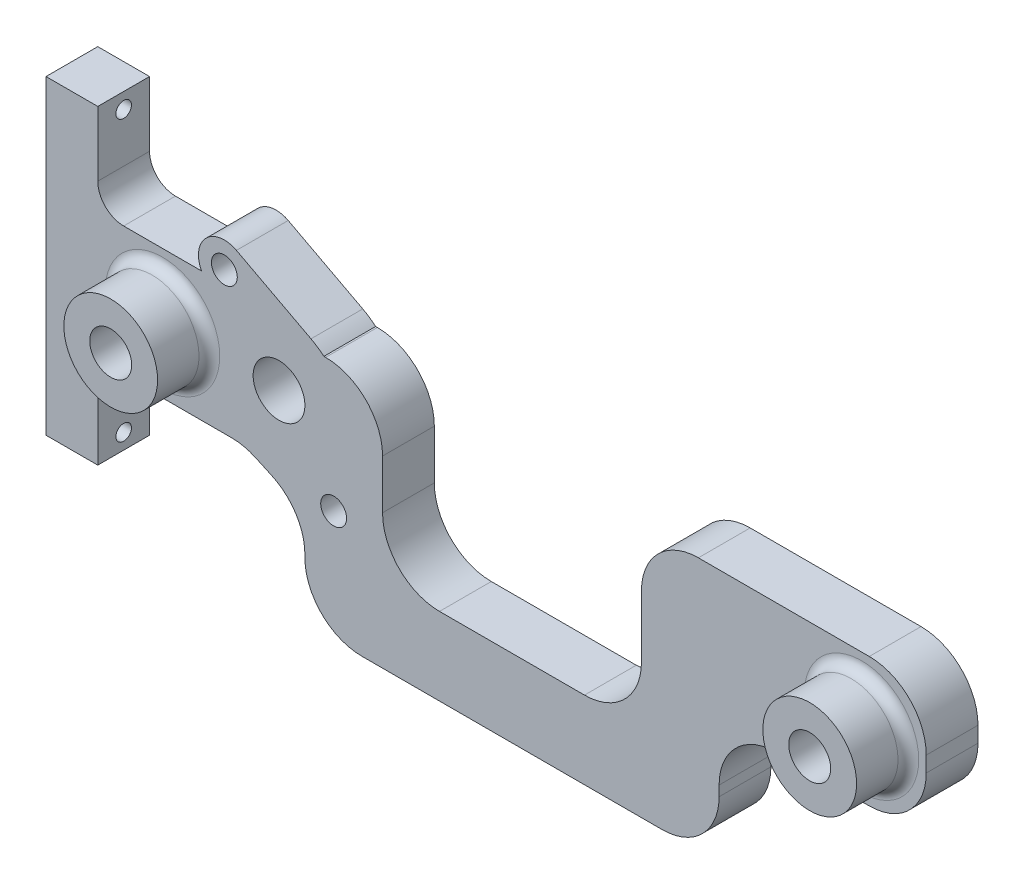
from build123d import *

# Parameters (mm, degrees)
SKETCH1_R           = 4.05
SKETCH1_R_2         = 5
SKETCH1_R_3         = 2.5
BOSS_EXTRUDE1_DEPTH = 10
FILLET1_R           = 11
SKETCH2_R           = 9.05
SKETCH2_R_2         = 4.05
BOSS_EXTRUDE2_DEPTH = 10
FILLET2_R           = 2
SKETCH3_W           = 10
SKETCH3_H           = 60
BOSS_EXTRUDE3_DEPTH = 10
FILLET3_R           = 5
SKETCH4_R           = 1.5
CUT_EXTRUDE1_DEPTH  = 10


with BuildPart() as part:
    # Sketch1 → Boss-Extrude1 (new body)
    with BuildSketch(Plane.XY):
        with BuildLine():
            Line((-80, -12.5), (-51.772571723, -12.5))
            Line((-51.772571723, -12.5), (-40, -17.854919158))
            Line((-40, -17.854919158), (-40, -36.461589484))
            Line((-40, -36.461589484), (40, -36.461589484))
            Line((40, -36.461589484), (40, -12.5))
            Line((40, -12.5), (80, -12.5))
            Line((80, -12.5), (80, 12.5))
            Line((80, 12.5), (25, 12.5))
            Line((25, 12.5), (25, -21.461589484))
            Line((25, -21.461589484), (-25, -21.461589484))
            Line((-25, -21.461589484), (-25, 10.023927765))
            Line((-25, 10.023927765), (-36.337703419, 10.023927765))
            ThreePointArc((-36.337703419, 10.023927765), (-37.531405043, 10.942330613), (-38.821632397, 11.719312422))
            Line((-38.821632397, 11.719312422), (-53.222645277, 19.311460171))
            ThreePointArc((-53.222645277, 19.311460171), (-59.112621671, 18.401196951), (-59.947052977, 12.5))
            Line((-59.947052977, 12.5), (-80, 12.5))
            Line((-80, 12.5), (-80, -12.5))
        make_face()
        with Locations((-67.5, 0)):
            Circle(SKETCH1_R, mode=Mode.SUBTRACT)
        with Locations((67.5, 0)):
            Circle(SKETCH1_R, mode=Mode.SUBTRACT)
        with Locations((-45, 0)):
            Circle(SKETCH1_R_2, mode=Mode.SUBTRACT)
        with Locations((-34.445576532, -14.888473571)):
            Circle(SKETCH1_R_3, mode=Mode.SUBTRACT)
        with Locations((-55.554423468, 14.888473571)):
            Circle(SKETCH1_R_3, mode=Mode.SUBTRACT)
    extrude(amount=BOSS_EXTRUDE1_DEPTH)

    # Fillet1
    fillet1_edges = [part.edges().sort_by_distance(p)[0] for p in [
        (80, 12.5, 5),
        (80, -12.5, 5),
        (40, -12.5, 5),
        (40, -36.461589484, 5),
        (-40, -36.461589484, 5),
        (-40, -17.854919158, 5),
        (-51.772571723, -12.5, 5),
        (-25, 10.023927765, 5),
        (-25, -21.461589484, 5),
        (25, -21.461589484, 5),
        (25, 12.5, 5),
    ]]
    fillet(fillet1_edges, radius=FILLET1_R)

    # Sketch2 → Boss-Extrude2 (add)
    with BuildSketch(Plane.XY.offset(10)):
        with Locations((-67.5, 0)):
            Circle(SKETCH2_R)
        with Locations((-67.5, 0)):
            Circle(SKETCH2_R_2, mode=Mode.SUBTRACT)
        with Locations((67.5, 0)):
            Circle(SKETCH2_R)
        with Locations((67.5, 0)):
            Circle(SKETCH2_R_2, mode=Mode.SUBTRACT)
    extrude(amount=BOSS_EXTRUDE2_DEPTH)

    # Fillet2
    fillet2_edges = [part.edges().sort_by_distance(p)[0] for p in [
        (-76.55, 0, 10),
        (58.45, 0, 10),
    ]]
    fillet(fillet2_edges, radius=FILLET2_R)

    # Sketch3 → Boss-Extrude3 (add)
    with BuildSketch(Plane.ZY.offset(80)):
        with Locations((5, 0)):
            Rectangle(SKETCH3_W, SKETCH3_H)
    extrude(amount=BOSS_EXTRUDE3_DEPTH)

    # Fillet3
    fillet3_edges = [part.edges().sort_by_distance(p)[0] for p in [
        (-80, -12.5, 5),
        (-80, 12.5, 5),
    ]]
    fillet(fillet3_edges, radius=FILLET3_R)

    # Sketch4 → Cut-Extrude1 (cut)
    with BuildSketch(Plane.ZY.offset(90)):
        with Locations((5, 27)):
            Circle(SKETCH4_R)
        with Locations((5, -27)):
            Circle(SKETCH4_R)
    extrude(amount=-CUT_EXTRUDE1_DEPTH, mode=Mode.SUBTRACT)


solid = part.part
